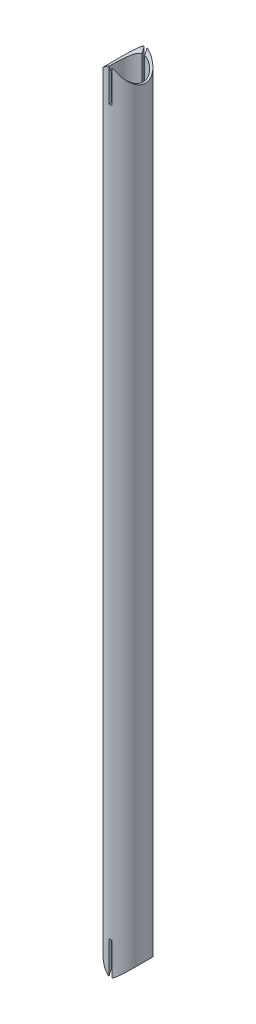
from build123d import *

# Parameters (mm, degrees)
SKETCH1_R           = 12.7
SKETCH1_R_2         = 11.05
BOSS_EXTRUDE1_DEPTH = 287.5
SKETCH2_R           = 13
CUT_EXTRUDE1_DEPTH  = 13.7
CUT_EXTRUDE2_START  = -13.700000103
SKETCH3_W           = 2
SKETCH3_H           = 53
CUT_EXTRUDE2_DEPTH  = 27.400000203


with BuildPart() as part:
    # Sketch1 → Boss-Extrude1 (new body, symmetric)
    with BuildSketch(Plane(origin=(0, 0, 0), x_dir=(1, 0, 0), z_dir=(0, 1, 0))):
        Circle(SKETCH1_R)
        Circle(SKETCH1_R_2, mode=Mode.SUBTRACT)
    extrude(amount=BOSS_EXTRUDE1_DEPTH, both=True)

    # Sketch2 → Cut-Extrude1 (cut, symmetric)
    with BuildSketch(Plane(origin=(0, 0, 0), x_dir=(0, 0, -1), z_dir=(1, 0, 0))):
        with Locations((0, -287.5)):
            Circle(SKETCH2_R)
    cut_extrude1 = extrude(amount=CUT_EXTRUDE1_DEPTH, both=True, mode=Mode.SUBTRACT)

    # Mirror1: Cut-Extrude1 across plane
    add(cut_extrude1.mirror(Plane.ZX), mode=Mode.SUBTRACT)

    # Sketch3 → Cut-Extrude2 (cut)
    with BuildSketch(Plane.XY.offset(CUT_EXTRUDE2_START)):
        with Locations((0, -287.5)):
            Rectangle(SKETCH3_W, SKETCH3_H)
    cut_extrude2 = extrude(amount=CUT_EXTRUDE2_DEPTH, mode=Mode.SUBTRACT)

    # Mirror2: Cut-Extrude2 across plane
    add(cut_extrude2.mirror(Plane.ZX), mode=Mode.SUBTRACT)


solid = part.part
